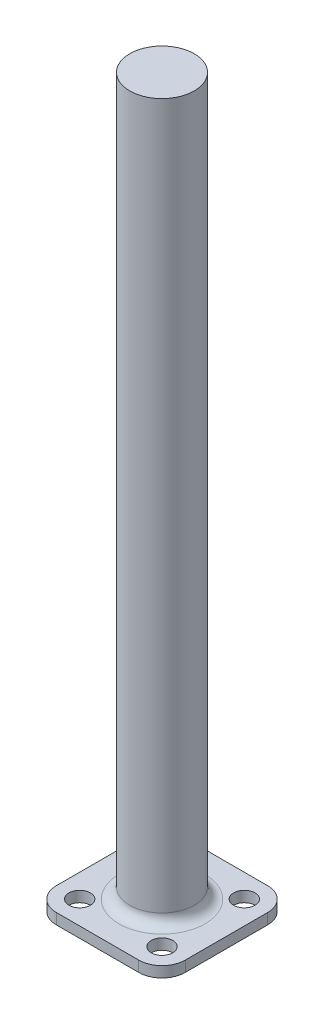
from build123d import *

# Parameters (mm, degrees)
SKETCH1_R           = 1.5
BOSS_EXTRUDE1_DEPTH = 1.5
SKETCH2_R           = 4.5
BOSS_EXTRUDE2_DEPTH = 100
FILLET2_R           = 1.5


with BuildPart() as part:
    # Sketch1 → Boss-Extrude1 (new body)
    with BuildSketch(Plane(origin=(0, 0, 0), x_dir=(1, 0, 0), z_dir=(0, 1, 0))):
        with BuildLine():
            Line((5.75, 9), (-5.75, 9))
            ThreePointArc((-5.75, 9), (-8.048097039, 8.048097039), (-9, 5.75))
            Line((-9, 5.75), (-9, -5.75))
            ThreePointArc((-9, -5.75), (-8.048097039, -8.048097039), (-5.75, -9))
            Line((-5.75, -9), (5.75, -9))
            ThreePointArc((5.75, -9), (8.048097039, -8.048097039), (9, -5.75))
            Line((9, -5.75), (9, 5.75))
            ThreePointArc((9, 5.75), (8.048097039, 8.048097039), (5.75, 9))
        make_face()
        with Locations((5.75, 5.75)):
            Circle(SKETCH1_R, mode=Mode.SUBTRACT)
        with Locations((5.75, -5.75)):
            Circle(SKETCH1_R, mode=Mode.SUBTRACT)
        with Locations((-5.75, -5.75)):
            Circle(SKETCH1_R, mode=Mode.SUBTRACT)
        with Locations((-5.75, 5.75)):
            Circle(SKETCH1_R, mode=Mode.SUBTRACT)
    extrude(amount=BOSS_EXTRUDE1_DEPTH)

    # Sketch2 → Boss-Extrude2 (add)
    with BuildSketch(Plane(origin=(0, 1.5, 0), x_dir=(1, 0, 0), z_dir=(0, 1, 0))):
        Circle(SKETCH2_R)
    extrude(amount=BOSS_EXTRUDE2_DEPTH)

    # Fillet2
    fillet2_edges = [part.edges().sort_by_distance(p)[0] for p in [
        (-4.5, 1.5, 0),
    ]]
    fillet(fillet2_edges, radius=FILLET2_R)


solid = part.part
